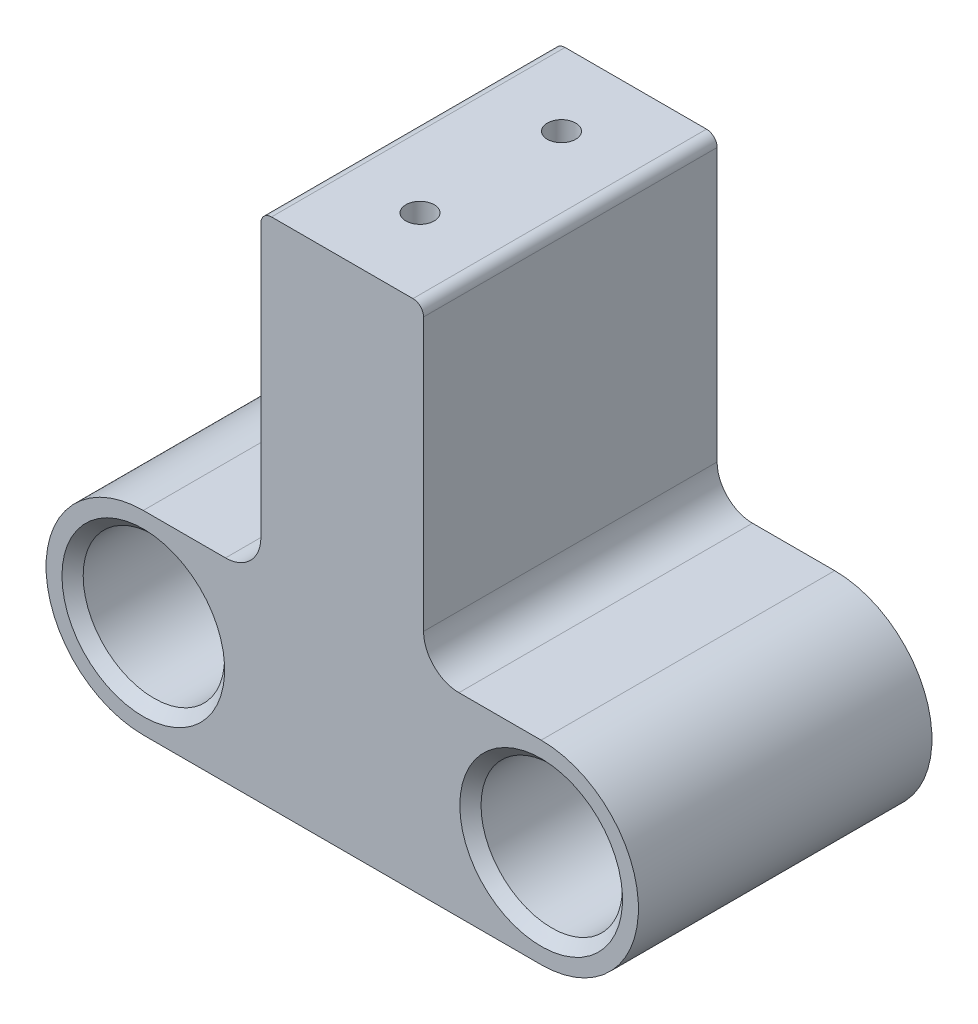
from build123d import *

# Parameters (mm, degrees)
SKETCH1_R                                        = 1.27
BOSS_EXTRUDE1_DEPTH                              = 25.4
CSK_FOR_1_4_FLAT_HEAD_MACHINE_SCREW1_D           = 6.7564
CSK_FOR_1_4_FLAT_HEAD_MACHINE_SCREW1_CSINK_D     = 13.3194044
CSK_FOR_1_4_FLAT_HEAD_MACHINE_SCREW1_CSINK_ANGLE = 82
SKETCH4_R                                        = 1.016
CUT_EXTRUDE1_DEPTH                               = 40.37
SKETCH5_W                                        = 65.738203623
SKETCH5_H                                        = 8.173238607
CUT_EXTRUDE2_DEPTH                               = 40.37
FILLET1_R                                        = 0.762
SKETCH8_W                                        = 13.691843982
SKETCH8_H                                        = 25.635792988
SKETCH8_W_2                                      = 17.381844488
SKETCH8_H_2                                      = 26.703951029
CUT_EXTRUDE3_DEPTH                               = 22.082
SKETCH9_R                                        = 5.08
CUT_EXTRUDE4_DEPTH                               = 11.557
CHAMFER1_SIZE                                    = 0.762
SKETCH10_W                                       = 31.402844339
SKETCH10_H                                       = 33.249058222
SKETCH10_W_2                                     = 26.204679654
SKETCH10_H_2                                     = 29.468553059
CUT_EXTRUDE5_DEPTH                               = 2.54
SKETCH11_W                                       = 51.569967854
SKETCH11_H                                       = 49.340439169
CUT_EXTRUDE6_DEPTH                               = 22.082
FILLET3_R                                        = 2.54


with BuildPart() as part:
    # Sketch1 → Boss-Extrude1 (new body)
    with BuildSketch(Plane.XY):
        Polygon((-5.842, 18.669), (-5.842, -1.651), (-28.575, -1.651), (-28.575, -20.701), (28.575, -20.701), (28.575, -1.651), (5.842, -1.651), (5.842, 18.669), align=None)
        with Locations((14.2875, -11.176)):
            Circle(SKETCH1_R, mode=Mode.SUBTRACT)
        with Locations((-14.2875, -11.176)):
            Circle(SKETCH1_R, mode=Mode.SUBTRACT)
    extrude(amount=BOSS_EXTRUDE1_DEPTH)

    # CSK for 1/4 Flat Head Machine Screw1 (through all)
    with Locations(Plane.XY.offset(25.4)):
        with Locations((-14.2875, -11.176), (14.2875, -11.176)):
            CounterSinkHole(CSK_FOR_1_4_FLAT_HEAD_MACHINE_SCREW1_D / 2, CSK_FOR_1_4_FLAT_HEAD_MACHINE_SCREW1_CSINK_D / 2, counter_sink_angle=CSK_FOR_1_4_FLAT_HEAD_MACHINE_SCREW1_CSINK_ANGLE)

    # Sketch4 → Cut-Extrude1 (cut, through all)
    with BuildSketch(Plane(origin=(0, 18.669, 0), x_dir=(1, 0, 0), z_dir=(0, 1, 0))):
        with Locations(Location((0, -5.334, 0), (0, 0, 270))):  # turned: the seam where the file's is
            Circle(SKETCH4_R)
        with Locations(Location((0, -15.494, 0), (0, 0, 90))):  # turned: the seam where the file's is
            Circle(SKETCH4_R)
    extrude(amount=-CUT_EXTRUDE1_DEPTH, mode=Mode.SUBTRACT)

    # Sketch5 → Cut-Extrude2 (cut, through all)
    with BuildSketch(Plane(origin=(0, 18.669, 0), x_dir=(1, 0, 0), z_dir=(0, 1, 0))):
        with Locations((0.634161588, -25.168619304)):
            Rectangle(SKETCH5_W, SKETCH5_H)
    extrude(amount=-CUT_EXTRUDE2_DEPTH, mode=Mode.SUBTRACT)

    # Fillet1
    fillet1_edges = [part.edges().sort_by_distance(p)[0] for p in [
        (-5.842, 18.669, 10.541),
        (5.842, 18.669, 10.541),
    ]]
    fillet(fillet1_edges, radius=FILLET1_R)

    # Sketch8 → Cut-Extrude3 (cut, through all)
    with BuildSketch(Plane.XY.offset(21.082)):
        with Locations((30.340921991, -12.055237245)):
            Rectangle(SKETCH8_W, SKETCH8_H)
        with Locations((-32.185922244, -9.773263248)):
            Rectangle(SKETCH8_W_2, SKETCH8_H_2)
    extrude(amount=-CUT_EXTRUDE3_DEPTH, mode=Mode.SUBTRACT)

    # Sketch9 → Cut-Extrude4 (cut)
    with BuildSketch(Plane.XY.offset(21.082)):
        with Locations((14.2875, -11.176)):
            Circle(SKETCH9_R)
        with Locations((-14.2875, -11.176)):
            Circle(SKETCH9_R)
    extrude(amount=-CUT_EXTRUDE4_DEPTH, mode=Mode.SUBTRACT)

    # Chamfer1
    chamfer1_edges = [part.edges().sort_by_distance(p)[0] for p in [
        (9.2075, -11.176, 21.082),
        (-19.3675, -11.176, 21.082),
        (0, -20.701, 4.318),
        (0, -20.701, 16.51),
    ]]
    chamfer(chamfer1_edges, length=CHAMFER1_SIZE)

    # Sketch10 → Cut-Extrude5 (cut)
    with BuildSketch(Plane(origin=(0, -1.651, 0), x_dir=(1, 0, 0), z_dir=(0, 1, 0))):
        with Locations((-21.54342217, -13.037102767)):
            Rectangle(SKETCH10_W, SKETCH10_H)
        with Locations((18.944339827, -12.019274454)):
            Rectangle(SKETCH10_W_2, SKETCH10_H_2)
    extrude(amount=-CUT_EXTRUDE5_DEPTH, mode=Mode.SUBTRACT)

    # Sketch11 → Cut-Extrude6 (cut, through all)
    with BuildSketch(Plane.XY.offset(21.082)):
        with Locations((0.48369004, -1.756987777)):
            Rectangle(SKETCH11_W, SKETCH11_H)
        with BuildLine():
            Line((14.2875, -4.191), (5.842, -4.191))
            Line((5.842, -4.191), (5.842, 17.907))
            ThreePointArc((5.842, 17.907), (5.618815367, 18.445815367), (5.08, 18.669))
            Line((5.08, 18.669), (-5.08, 18.669))
            ThreePointArc((-5.08, 18.669), (-5.618815367, 18.445815367), (-5.842, 17.907))
            Line((-5.842, 17.907), (-5.842, -4.191))
            Line((-5.842, -4.191), (-14.2875, -4.191))
            ThreePointArc((-14.2875, -4.191), (-21.2725, -11.176), (-14.2875, -18.161))
            Line((-14.2875, -18.161), (14.2875, -18.161))
            ThreePointArc((14.2875, -18.161), (21.2725, -11.176), (14.2875, -4.191))
        make_face(mode=Mode.SUBTRACT)
    extrude(amount=-CUT_EXTRUDE6_DEPTH, mode=Mode.SUBTRACT)

    # Fillet3
    fillet3_edges = [part.edges().sort_by_distance(p)[0] for p in [
        (-5.842, -4.191, 10.541),
        (5.842, -4.191, 10.541),
    ]]
    fillet(fillet3_edges, radius=FILLET3_R)


solid = part.part
